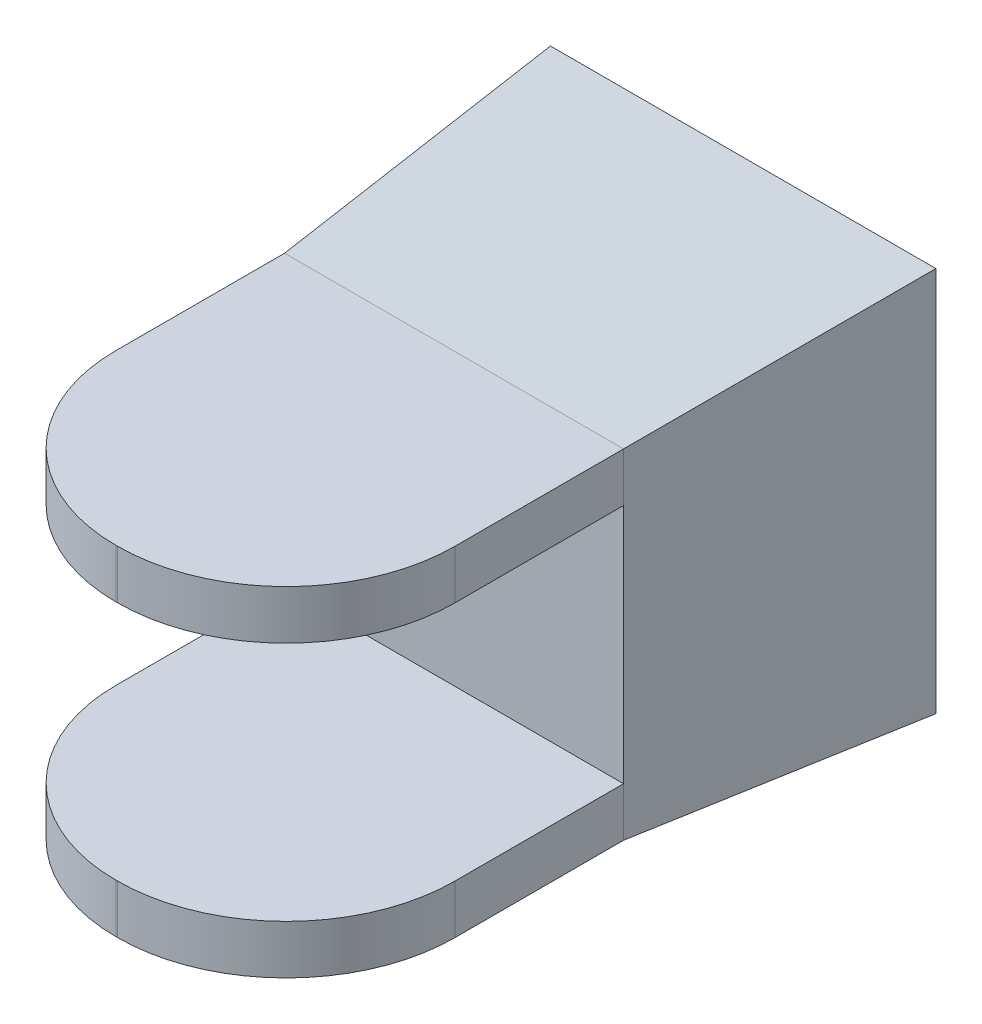
from build123d import *

# Parameters (mm, degrees)
SZKIC1_W                    = 80
SZKIC1_H                    = 80
DODANIE_WYCI_GNI_CIE1_DEPTH = 60
DODANIE_WYCI_GNI_CIE1_TAPER = 4.6
SZKIC6_W                    = 70.345029246
SZKIC6_H                    = 70.345029246
DODANIE_WYCI_GNI_CIE2_DEPTH = 70
ZAOKR_GLENIE3_R             = 35
ZAOKR_GLENIE4_R             = 35
SZKIC7_W                    = 70.345029246
SZKIC7_H                    = 50
WYTNIJ_WYCI_GNI_CIE3_DEPTH  = 70


with BuildPart() as part:
    # Szkic1 → Dodanie-wyciągnięcie1 (new body)
    with BuildSketch(Plane.XY):
        Rectangle(SZKIC1_W, SZKIC1_H)
    extrude(amount=DODANIE_WYCI_GNI_CIE1_DEPTH, taper=DODANIE_WYCI_GNI_CIE1_TAPER)

    # Szkic6 → Dodanie-wyciągnięcie2 (add)
    with BuildSketch(Plane.XY.offset(60)):
        Rectangle(SZKIC6_W, SZKIC6_H)
    extrude(amount=DODANIE_WYCI_GNI_CIE2_DEPTH)

    # Zaokrąglenie3
    zaokr_glenie3_edges = [part.edges().sort_by_distance(p)[0] for p in [
        (-35.172514623, 0, 130),
    ]]
    fillet(zaokr_glenie3_edges, radius=ZAOKR_GLENIE3_R)

    # Zaokrąglenie4
    zaokr_glenie4_edges = [part.edges().sort_by_distance(p)[0] for p in [
        (35.172514623, 0, 130),
    ]]
    fillet(zaokr_glenie4_edges, radius=ZAOKR_GLENIE4_R)

    # Szkic7 → Wytnij-wyciągnięcie3 (cut)
    with BuildSketch(Plane.XY.offset(130)):
        Rectangle(SZKIC7_W, SZKIC7_H)
    extrude(amount=-WYTNIJ_WYCI_GNI_CIE3_DEPTH, mode=Mode.SUBTRACT)


solid = part.part
